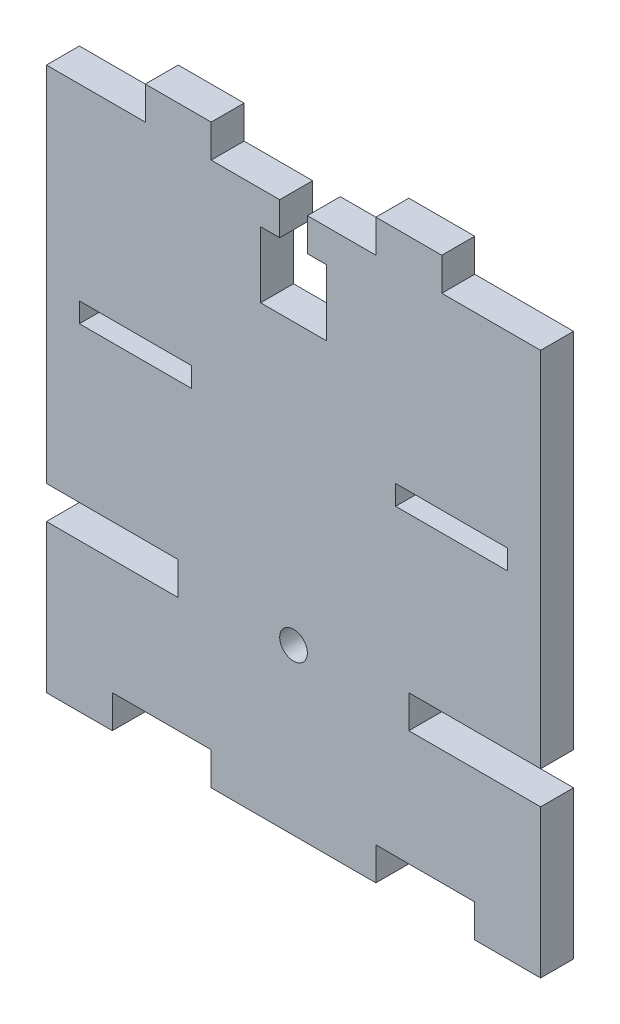
from build123d import *

# Parameters (mm, degrees)
SKETCH1_W           = 75
SKETCH1_H           = 17.5
SKETCH1_R           = 2.1
SKETCH1_W_2         = 10
SKETCH1_H_2         = 5
SKETCH1_W_3         = 25
BOSS_EXTRUDE1_DEPTH = 5
SKETCH2_W           = 75
SKETCH2_H           = 55
BOSS_EXTRUDE2_DEPTH = 5
SKETCH3_W           = 10
SKETCH3_H           = 5
BOSS_EXTRUDE3_DEPTH = 5
SKETCH4_W           = 4.2
SKETCH4_H           = 5
SKETCH4_H_2         = 3.2
SKETCH4_H_3         = 1.8
SKETCH4_W_2         = 1.4
CUT_EXTRUDE1_DEPTH  = 5
SKETCH5_W           = 10
SKETCH5_H           = 10
CUT_EXTRUDE2_DEPTH  = 5
SKETCH6_W           = 17.000000092
SKETCH6_H           = 3
CUT_EXTRUDE3_DEPTH  = 10


with BuildPart() as part:
    # Sketch1 → Boss-Extrude1 (new body)
    with BuildSketch(Plane.XY):
        with Locations((37.5, 8.75)):
            Rectangle(SKETCH1_W, SKETCH1_H)
        Polygon((20, 22.5), (20, 17.5), (55, 17.5), (55, 22.5), (41.830127019, 22.5), (33.169872981, 22.5), align=None)
        with Locations((37.5, 20)):
            Circle(SKETCH1_R, mode=Mode.SUBTRACT)
        with BuildLine():
            ThreePointArc((41.830127019, 22.5), (37.5, 25), (33.169872981, 22.5))
            Line((33.169872981, 22.5), (41.830127019, 22.5))
        make_face()
        Polygon((0, 17.5), (0, 0), (10, 0), (25, 0), (50, 0), (65, 0), (75, 0), (75, 17.5), (55, 17.5), (20, 17.5), align=None)
        with Locations((70, -2.5)):
            Rectangle(SKETCH1_W_2, SKETCH1_H_2)
        with Locations((37.5, -2.5)):
            Rectangle(SKETCH1_W_3, SKETCH1_H_2)
        with Locations((5, -2.5)):
            Rectangle(SKETCH1_W_2, SKETCH1_H_2)
    extrude(amount=BOSS_EXTRUDE1_DEPTH)

    # Sketch2 → Boss-Extrude2 (add)
    with BuildSketch(Plane(origin=(0, 0, 0), x_dir=(-1, 0, 0), z_dir=(0, 0, -1))):
        with Locations((-37.5, 50)):
            Rectangle(SKETCH2_W, SKETCH2_H)
    extrude(amount=-BOSS_EXTRUDE2_DEPTH)

    # Sketch3 → Boss-Extrude3 (add)
    with BuildSketch(Plane(origin=(0, 0, 0), x_dir=(-1, 0, 0), z_dir=(0, 0, -1))):
        with Locations((-55, 80)):
            Rectangle(SKETCH3_W, SKETCH3_H)
        with Locations((-20, 80)):
            Rectangle(SKETCH3_W, SKETCH3_H)
    extrude(amount=-BOSS_EXTRUDE3_DEPTH)

    # Sketch4 → Cut-Extrude1 (cut)
    with BuildSketch(Plane(origin=(0, 0, 0), x_dir=(-1, 0, 0), z_dir=(0, 0, -1))):
        with Locations((-37.5, 75)):
            Rectangle(SKETCH4_W, SKETCH4_H)
        with Locations((-37.5, 70.9)):
            Rectangle(SKETCH4_W, SKETCH4_H_2)
        with Locations((-37.5, 68.4)):
            Rectangle(SKETCH4_W, SKETCH4_H_3)
        with Locations((-40.3, 70.9)):
            Rectangle(SKETCH4_W_2, SKETCH4_H_2)
        with Locations((-34.7, 70.9)):
            Rectangle(SKETCH4_W_2, SKETCH4_H_2)
    extrude(amount=-CUT_EXTRUDE1_DEPTH, mode=Mode.SUBTRACT)

    # Sketch5 → Cut-Extrude2 (cut)
    with BuildSketch(Plane(origin=(0, 0, 0), x_dir=(-1, 0, 0), z_dir=(0, 0, -1))):
        with Locations((-37.5, 67.5)):
            Rectangle(SKETCH5_W, SKETCH5_H)
    extrude(amount=-CUT_EXTRUDE2_DEPTH, mode=Mode.SUBTRACT)

    # Sketch6 → Cut-Extrude3 (cut)
    with BuildSketch(Plane(origin=(0, 0, 0), x_dir=(-1, 0, 0), z_dir=(0, 0, -1))):
        with Locations((-61.499999954, 47.499999965)):
            Rectangle(SKETCH6_W, SKETCH6_H)
        with Locations((-13.500000046, 47.499999965)):
            Rectangle(SKETCH6_W, SKETCH6_H)
    extrude(amount=-CUT_EXTRUDE3_DEPTH, mode=Mode.SUBTRACT)


solid = part.part
